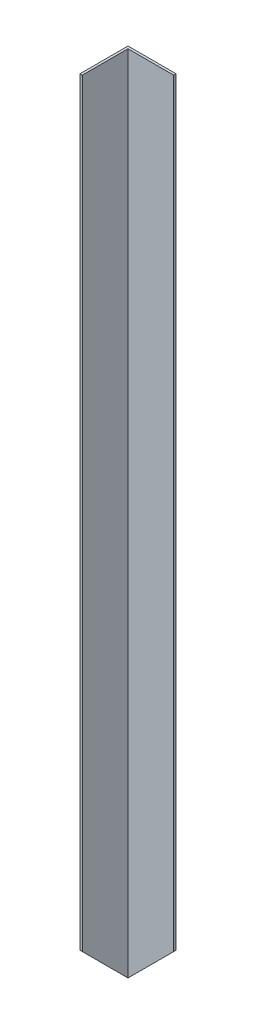
from build123d import *

# Parameters (mm, degrees)
BOSS_EXTRU_1_DEPTH      = 672
ENL_V_MAT_EXTRU_1_DEPTH = 590
ENL_V_MAT_EXTRU_2_DEPTH = 590


with BuildPart() as part:
    # Esquisse1 → Boss.-Extru.1 (new body)
    with BuildSketch(Plane(origin=(0, 0, 0), x_dir=(1, 0, 0), z_dir=(0, 1, 0))):
        Polygon((-20, 20.113636364), (20, 20.113636364), (20, 18.113636364), (-18, 18.113636364), (-18, -19.886363636), (-20, -19.886363636), align=None)
    extrude(amount=BOSS_EXTRU_1_DEPTH)

    # Esquisse2 → Enlèv. mat.-Extru.1 (cut)
    with BuildSketch(Plane(origin=(0, 0, -20.113636364), x_dir=(-1, 0, 0), z_dir=(0, 0, -1))):
        Polygon((20, 0), (-20, 40), (-20, 0), align=None)
    extrude(amount=-ENL_V_MAT_EXTRU_1_DEPTH, mode=Mode.SUBTRACT)

    # Esquisse3 → Enlèv. mat.-Extru.2 (cut)
    with BuildSketch(Plane.ZY.offset(20)):
        Polygon((-20.113636364, 0), (19.886363636, 40), (19.886363636, 0), align=None)
    extrude(amount=-ENL_V_MAT_EXTRU_2_DEPTH, mode=Mode.SUBTRACT)


solid = part.part
